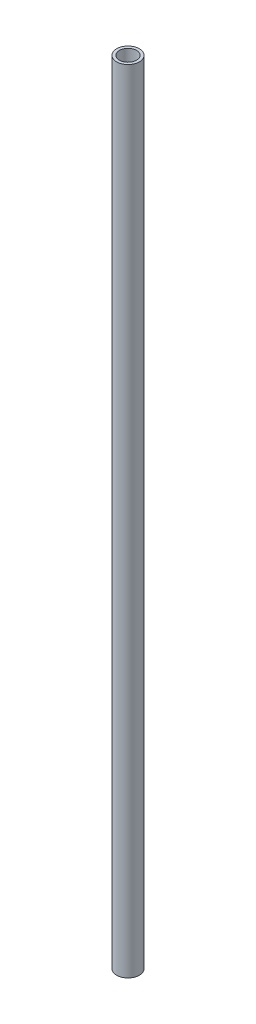
from build123d import *

# Parameters (mm, degrees)
SKETCH1_R           = 2
SKETCH1_R_2         = 1.5
BOSS_EXTRUDE1_DEPTH = 69.5


with BuildPart() as part:
    # Sketch1 → Boss-Extrude1 (new body, symmetric)
    with BuildSketch(Plane(origin=(0, 0, 0), x_dir=(1, 0, 0), z_dir=(0, 1, 0))):
        Circle(SKETCH1_R)
        Circle(SKETCH1_R_2, mode=Mode.SUBTRACT)
    extrude(amount=BOSS_EXTRUDE1_DEPTH, both=True)


solid = part.part
